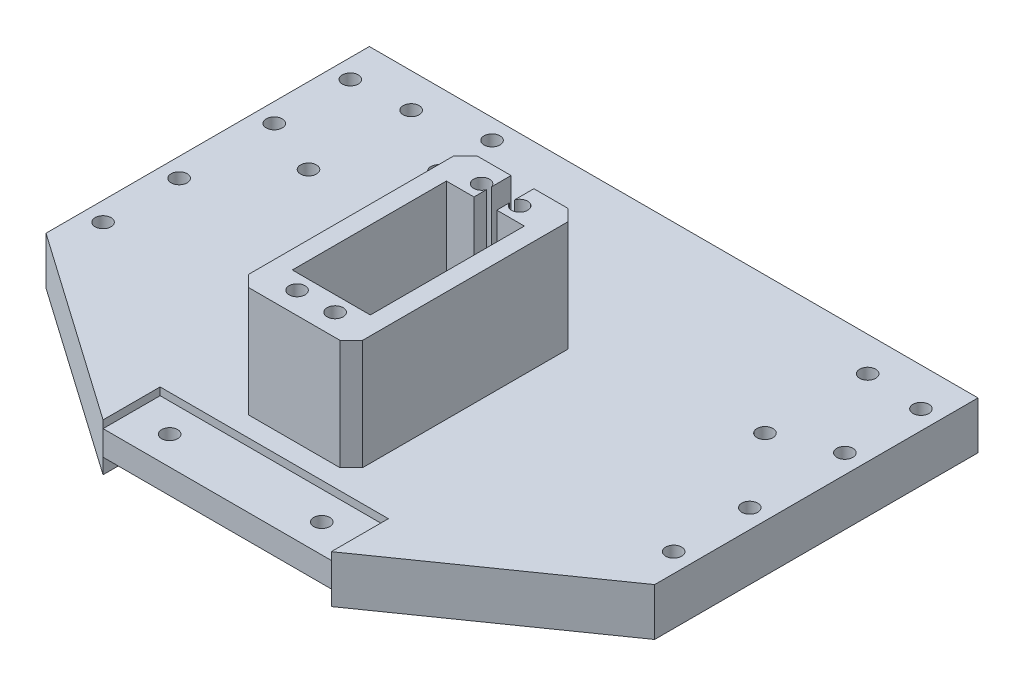
from build123d import *

# Parameters (mm, degrees)
BOSS_EXTRUDE2_DEPTH = 12.5
SKETCH2_R           = 2.1
BOSS_EXTRUDE3_DEPTH = 29
SKETCH4_W           = 9
SKETCH4_H           = 3.5
CUT_EXTRUDE1_DEPTH  = 73
CHAMFER1_SIZE       = 3
SKETCH5_W           = 60
SKETCH5_H           = 15
SKETCH5_R           = 2.89755201
CUT_EXTRUDE2_DEPTH  = 4
SKETCH6_R           = 2.89755201
CUT_EXTRUDE3_DEPTH  = 26
SKETCH7_R           = 2.1
CUT_EXTRUDE4_DEPTH  = 26
SKETCH8_R           = 2.1
CUT_EXTRUDE5_DEPTH  = 26
SKETCH9_W           = 20
SKETCH9_H           = 45
CUT_EXTRUDE8_DEPTH  = 5
SKETCH10_W          = 1.5
SKETCH10_H          = 3.5
BOSS_EXTRUDE4_DEPTH = 9.75
SKETCH11_R          = 2.1
CUT_EXTRUDE9_DEPTH  = 22
SKETCH12_R          = 2.89755201
SKETCH12_R_2        = 2.1
BOSS_EXTRUDE6_DEPTH = 8.5
SKETCH13_W          = 1.5
SKETCH13_H          = 3.5
CUT_EXTRUDE10_DEPTH = 14.2
SKETCH14_W          = 60
SKETCH14_H          = 15
CUT_EXTRUDE11_DEPTH = 2
BOSS_EXTRUDE7_REACH = 43.5
SKETCH15_R          = 2.1


with BuildPart() as part:
    # Sketch1 → Boss-Extrude2 (new body)
    with BuildSketch(Plane(origin=(0, 0, 0), x_dir=(1, 0, 0), z_dir=(0, 1, 0))):
        Polygon((-80, -42.5), (-80, 42.5), (80, 42.5), (80, -42.5), (30, -77.5), (-30, -77.5), align=None)
    extrude(amount=BOSS_EXTRUDE2_DEPTH)

    # Sketch2 → Boss-Extrude3 (add)
    with BuildSketch(Plane(origin=(0, 12.5, 0), x_dir=(1, 0, 0), z_dir=(0, 1, 0))):
        with BuildLine():
            Line((10.25, -47.5), (-10.25, -47.5))
            Line((-10.25, -47.5), (-10.25, -7))
            Line((-10.25, -7), (-3, -7))
            Line((-3, -7), (-3, -3.640312424))
            ThreePointArc((-3, -3.640312424), (-7.1, -3), (-3, -2.359687576))
            Line((-3, -2.359687576), (-3, 2.75))
            Line((-3, 2.75), (-15, 2.75))
            Line((-15, 2.75), (-15, -57.25))
            Line((-15, -57.25), (15, -57.25))
            Line((15, -57.25), (15, 2.75))
            Line((15, 2.75), (3, 2.75))
            Line((3, 2.75), (3, -2.359687576))
            ThreePointArc((3, -2.359687576), (5.324037035, -0.925150608), (7.1, -3))
            ThreePointArc((7.1, -3), (5.324037035, -5.074849392), (3, -3.640312424))
            Line((3, -3.640312424), (3, -7))
            Line((3, -7), (10.25, -7))
            Line((10.25, -7), (10.25, -47.5))
        make_face()
        with Locations((-5, -51.5)):
            Circle(SKETCH2_R, mode=Mode.SUBTRACT)
        with Locations((5, -51.5)):
            Circle(SKETCH2_R, mode=Mode.SUBTRACT)
    extrude(amount=BOSS_EXTRUDE3_DEPTH)

    # Sketch4 → Cut-Extrude1 (cut)
    with BuildSketch(Plane.XY.offset(57.25)):
        with Locations((5, 35.75)):
            Rectangle(SKETCH4_W, SKETCH4_H)
        with Locations((-5, 35.75)):
            Rectangle(SKETCH4_W, SKETCH4_H)
    extrude(amount=-CUT_EXTRUDE1_DEPTH, mode=Mode.SUBTRACT)

    # Chamfer1
    chamfer1_edges = [part.edges().sort_by_distance(p)[0] for p in [
        (-15, 27, -2.75),
        (-15, 27, 57.25),
        (15, 27, 57.25),
        (15, 27, -2.75),
    ]]
    chamfer(chamfer1_edges, length=CHAMFER1_SIZE)

    # Sketch5 → Cut-Extrude2 (cut)
    with BuildSketch(Plane.XZ):
        with Locations((0, 70)):
            Rectangle(SKETCH5_W, SKETCH5_H)
        with Locations((-20, 70)):
            Circle(SKETCH5_R, mode=Mode.SUBTRACT)
        with Locations((20, 70)):
            Circle(SKETCH5_R, mode=Mode.SUBTRACT)
    extrude(amount=-CUT_EXTRUDE2_DEPTH, mode=Mode.SUBTRACT)

    # Sketch6 → Cut-Extrude3 (cut)
    with BuildSketch(Plane(origin=(0, 0, 0), x_dir=(-1, 0, 0), z_dir=(0, -1, 0))):
        with Locations((20, -70)):
            Circle(SKETCH6_R)
        with Locations((-20, -70)):
            Circle(SKETCH6_R)
    extrude(amount=-CUT_EXTRUDE3_DEPTH, mode=Mode.SUBTRACT)

    # Sketch7 → Cut-Extrude4 (cut)
    with BuildSketch(Plane(origin=(0, 12.5, 0), x_dir=(1, 0, 0), z_dir=(0, 1, 0))):
        with Locations((-75, 32.5)):
            Circle(SKETCH7_R)
        with Locations((-75, 12.5)):
            Circle(SKETCH7_R)
        with Locations((-75, -12.5)):
            Circle(SKETCH7_R)
        with Locations((-75, -32.5)):
            Circle(SKETCH7_R)
        with Locations((75, -32.5)):
            Circle(SKETCH7_R)
        with Locations((75, -12.5)):
            Circle(SKETCH7_R)
        with Locations((75, 12.5)):
            Circle(SKETCH7_R)
        with Locations((75, 32.5)):
            Circle(SKETCH7_R)
    extrude(amount=-CUT_EXTRUDE4_DEPTH, mode=Mode.SUBTRACT)

    # Sketch8 → Cut-Extrude5 (cut)
    with BuildSketch(Plane.XZ):
        with Locations((-60, -6.5)):
            Circle(SKETCH8_R)
        with Locations((-60, -33.5)):
            Circle(SKETCH8_R)
        with Locations((60, -6.5)):
            Circle(SKETCH8_R)
        with Locations((60, -33.5)):
            Circle(SKETCH8_R)
    extrude(amount=-CUT_EXTRUDE5_DEPTH, mode=Mode.SUBTRACT)

    # Sketch9 → Cut-Extrude8 (cut)
    with BuildSketch(Plane.XZ):
        with Locations((-60, -20)):
            Rectangle(SKETCH9_W, SKETCH9_H)
        with Locations((60, -20)):
            Rectangle(SKETCH9_W, SKETCH9_H)
    extrude(amount=-CUT_EXTRUDE8_DEPTH, mode=Mode.SUBTRACT)

    # Sketch10 → Boss-Extrude4 (add)
    with BuildSketch(Plane.XY.offset(57.25)):
        with Locations((0, 35.75)):
            Rectangle(SKETCH10_W, SKETCH10_H)
    extrude(amount=-BOSS_EXTRUDE4_DEPTH)

    # Sketch11 → Cut-Extrude9 (cut)
    with BuildSketch(Plane(origin=(0, 12.5, 0), x_dir=(1, 0, 0), z_dir=(0, 1, 0))):
        with Locations((-42.5, 37.25)):
            Circle(SKETCH11_R)
        with Locations((-42.5, 23.25)):
            Circle(SKETCH11_R)
    extrude(amount=-CUT_EXTRUDE9_DEPTH, mode=Mode.SUBTRACT)

    # Sketch12 → Boss-Extrude6 (add)
    with BuildSketch(Plane(origin=(0, 12.5, 0), x_dir=(1, 0, 0), z_dir=(0, 1, 0))):
        with Locations((-20, -70)):
            Circle(SKETCH12_R)
        with Locations((-20, -70)):
            Circle(SKETCH12_R_2, mode=Mode.SUBTRACT)
        with Locations((20, -70)):
            Circle(SKETCH12_R)
        with Locations((20, -70)):
            Circle(SKETCH12_R_2, mode=Mode.SUBTRACT)
    extrude(amount=-BOSS_EXTRUDE6_DEPTH)

    # Sketch13 → Cut-Extrude10 (cut)
    with BuildSketch(Plane.XY.offset(57.25)):
        with Locations((0, 35.75)):
            Rectangle(SKETCH13_W, SKETCH13_H)
    extrude(amount=-CUT_EXTRUDE10_DEPTH, mode=Mode.SUBTRACT)

    # Sketch14 → Cut-Extrude11 (cut)
    with BuildSketch(Plane(origin=(0, 12.5, 0), x_dir=(1, 0, 0), z_dir=(0, 1, 0))):
        with Locations((0, -70)):
            Rectangle(SKETCH14_W, SKETCH14_H)
    extrude(amount=-CUT_EXTRUDE11_DEPTH, mode=Mode.SUBTRACT)

    # Sketch15 → Boss-Extrude7 (add, up to next)
    with BuildSketch(Plane(origin=(0, 41.5, 0), x_dir=(1, 0, 0), z_dir=(0, 1, 0)), mode=Mode.PRIVATE) as boss_extrude7_sk1:
        Polygon((-12, -47.5), (-12, -57.25), (12, -57.25), (12, -47.5), (10.25, -47.5), (-10.25, -47.5), align=None)
        with Locations((-5, -51.5)):
            Circle(SKETCH15_R, mode=Mode.SUBTRACT)
        with Locations((5, -51.5)):
            Circle(SKETCH15_R, mode=Mode.SUBTRACT)
    boss_extrude7_tool1 = extrude(boss_extrude7_sk1.sketch, amount=-BOSS_EXTRUDE7_REACH, mode=Mode.PRIVATE) - part.part
    add(boss_extrude7_tool1.solids().sort_by_distance((0, 41.5, 52.492529))[0])
    # Sketch15 → Boss-Extrude7 (add, up to next)
    with BuildSketch(Plane(origin=(0, 41.5, 0), x_dir=(1, 0, 0), z_dir=(0, 1, 0)), mode=Mode.PRIVATE) as boss_extrude7_sk2:
        with BuildLine():
            Line((12, 2.75), (3, 2.75))
            Line((3, 2.75), (3, -2.359687576))
            ThreePointArc((3, -2.359687576), (5.324037035, -0.925150608), (7.1, -3))
            ThreePointArc((7.1, -3), (5.324037035, -5.074849392), (3, -3.640312424))
            Line((3, -3.640312424), (3, -7))
            Line((3, -7), (10.25, -7))
            Line((10.25, -7), (12.122605781, -7))
            Line((12.122605781, -7), (12.122605781, 2.627394219))
            Line((12.122605781, 2.627394219), (12, 2.75))
        make_face()
    boss_extrude7_tool2 = extrude(boss_extrude7_sk2.sketch, amount=-BOSS_EXTRUDE7_REACH, mode=Mode.PRIVATE) - part.part
    add(boss_extrude7_tool2.solids().sort_by_distance((8.027672, 41.5, 1.965211))[0])
    # Sketch15 → Boss-Extrude7 (add, up to next)
    with BuildSketch(Plane(origin=(0, 41.5, 0), x_dir=(1, 0, 0), z_dir=(0, 1, 0)), mode=Mode.PRIVATE) as boss_extrude7_sk3:
        with BuildLine():
            Line((-3, 2.75), (-12, 2.75))
            Line((-12, 2.75), (-12, -7))
            Line((-12, -7), (-10.25, -7))
            Line((-10.25, -7), (-3, -7))
            Line((-3, -7), (-3, -3.640312424))
            ThreePointArc((-3, -3.640312424), (-7.1, -3), (-3, -2.359687576))
            Line((-3, -2.359687576), (-3, 2.75))
        make_face()
    boss_extrude7_tool3 = extrude(boss_extrude7_sk3.sketch, amount=-BOSS_EXTRUDE7_REACH, mode=Mode.PRIVATE) - part.part
    add(boss_extrude7_tool3.solids().sort_by_distance((-7.962908, 41.5, 1.962154))[0])


solid = part.part
